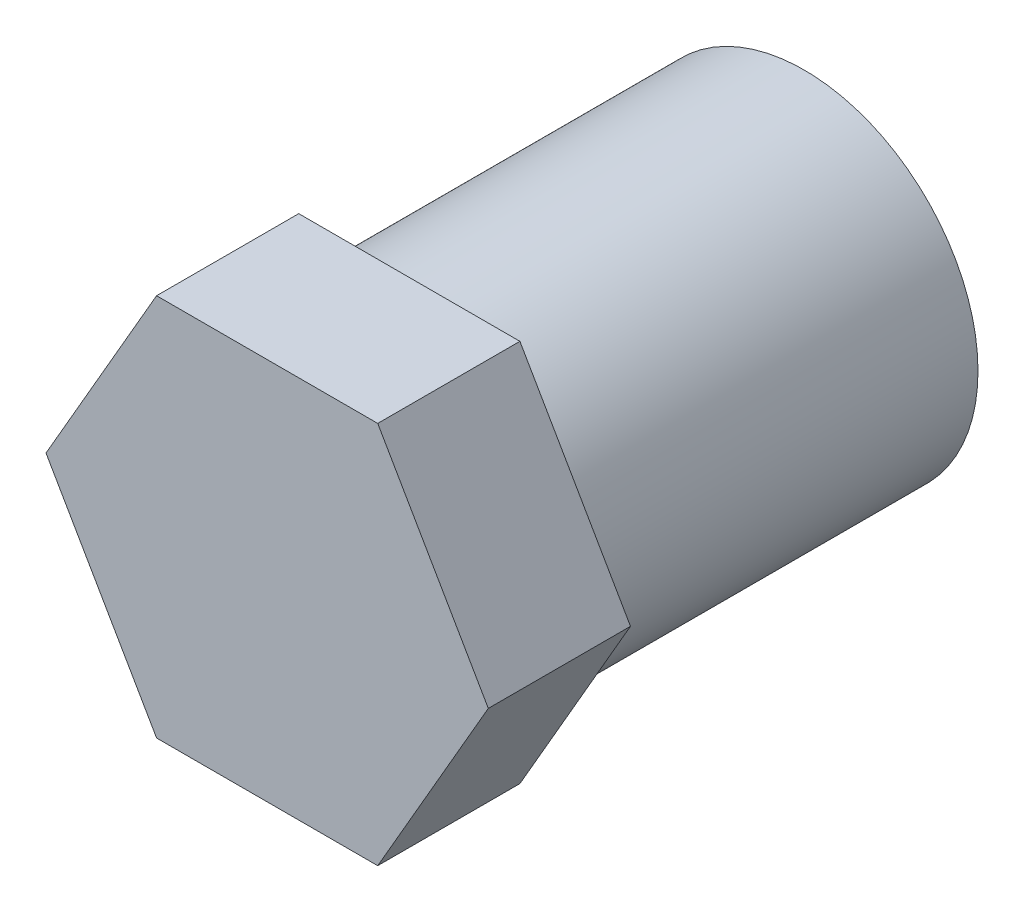
from build123d import *

# Parameters (mm, degrees)
SKETCH_1_R      = 5.5
SKETCH_1_R_2    = 2.5
EXTRUDE_1_DEPTH = 12.5
EXTRUDE_2_DEPTH = 4.5


with BuildPart() as part:
    # 草图1 → 凸台-拉伸1 (new body)
    with BuildSketch(Plane.XY):
        Circle(SKETCH_1_R)
        Circle(SKETCH_1_R_2, mode=Mode.SUBTRACT)
    extrude(amount=EXTRUDE_1_DEPTH)

    # 草图2 → 凸台-拉伸2 (add)
    with BuildSketch(Plane.XY.offset(12.5)):
        Polygon((-3.5, 6.062177826), (3.5, 6.062177826), (7, 0), (3.5, -6.062177826), (-3.5, -6.062177826), (-7, 0), align=None)
    extrude(amount=EXTRUDE_2_DEPTH)


solid = part.part
